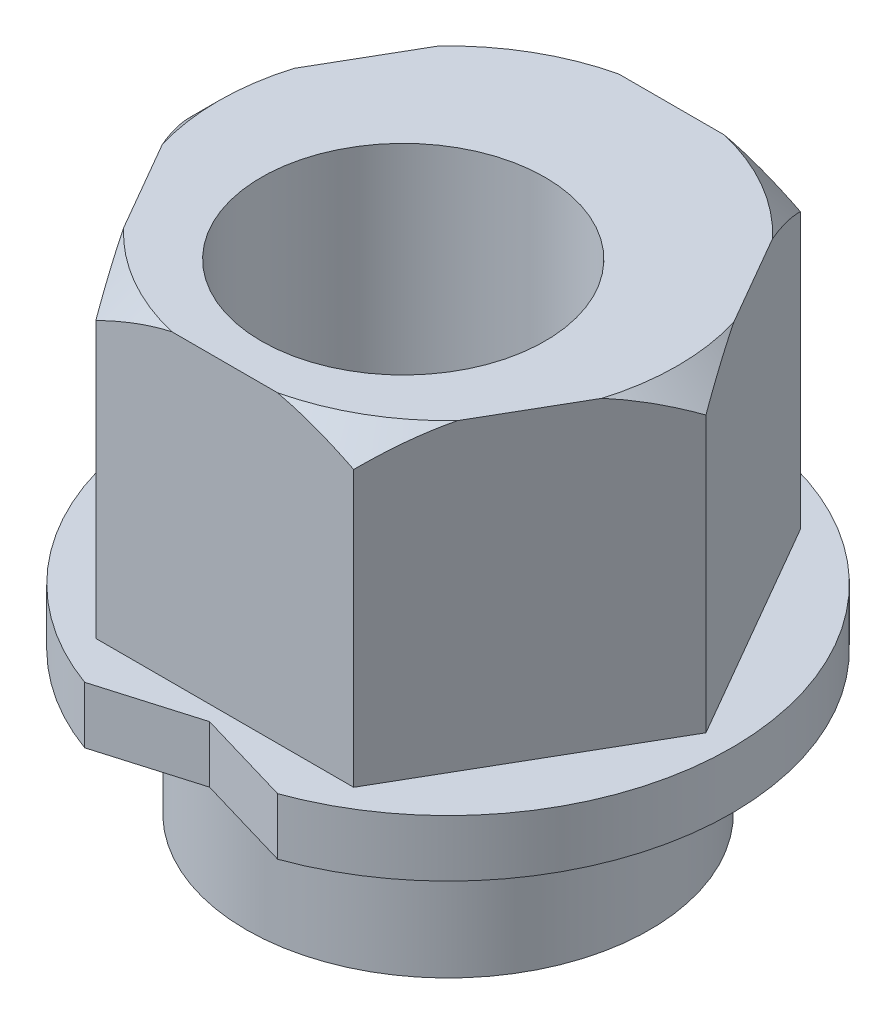
from build123d import *

# Parameters (mm, degrees)
BOSS_EXTRUDE1_DEPTH = 5.35
SKETCH2_R           = 5
BOSS_EXTRUDE2_DEPTH = 1
SKETCH3_R           = 3.555
BOSS_EXTRUDE3_DEPTH = 2.5
SKETCH4_R           = 2.5
CUT_EXTRUDE1_DEPTH  = 9.85
CUT_EXTRUDE2_DEPTH  = 4.5


with BuildPart() as part:
    # Sketch1 → Boss-Extrude1 (new body)
    with BuildSketch(Plane(origin=(0, 0, 0), x_dir=(1, 0, 0), z_dir=(0, 1, 0))):
        Polygon((4.543746619, 0), (2.271873309, 3.935), (-2.271873309, 3.935), (-4.543746619, 0), (-2.271873309, -3.935), (2.271873309, -3.935), align=None)
    extrude(amount=BOSS_EXTRUDE1_DEPTH)

    # Sketch2 → Boss-Extrude2 (add)
    with BuildSketch(Plane(origin=(0, 0, 0), x_dir=(1, 0, 0), z_dir=(0, 1, 0))):
        Circle(SKETCH2_R)
    extrude(amount=-BOSS_EXTRUDE2_DEPTH)

    # Sketch3 → Boss-Extrude3 (add)
    with BuildSketch(Plane.XZ.offset(1)):
        Circle(SKETCH3_R)
    extrude(amount=BOSS_EXTRUDE3_DEPTH)

    # Sketch4 → Cut-Extrude1 (cut, through all)
    with BuildSketch(Plane(origin=(0, 5.35, 0), x_dir=(1, 0, 0), z_dir=(0, 1, 0))):
        with Locations((0, -0.79)):
            Circle(SKETCH4_R)
    extrude(amount=-CUT_EXTRUDE1_DEPTH, mode=Mode.SUBTRACT)

    # Sketch5 → Cut-Extrude2 (cut, through all)
    with BuildSketch(Plane(origin=(0, 0, 0), x_dir=(1, 0, 0), z_dir=(0, 1, 0))):
        with BuildLine():
            Line((-1.7, -4.702127178), (0, -4.202127178))
            Line((0, -4.202127178), (1.7, -4.702127178))
            ThreePointArc((1.7, -4.702127178), (0, -5), (-1.7, -4.702127178))
        make_face()
    extrude(amount=-CUT_EXTRUDE2_DEPTH, mode=Mode.SUBTRACT)

    # Sketch6 → Cut-Revolve1 (revolve, cut)
    with BuildSketch(Plane.XY):
        Polygon((4.043746619, 5.35), (4.543746619, 5.35), (4.543746619, 4.85), align=None)
    revolve(axis=Axis((0, 0, 0), (0, 1, 0)), mode=Mode.SUBTRACT)


solid = part.part
